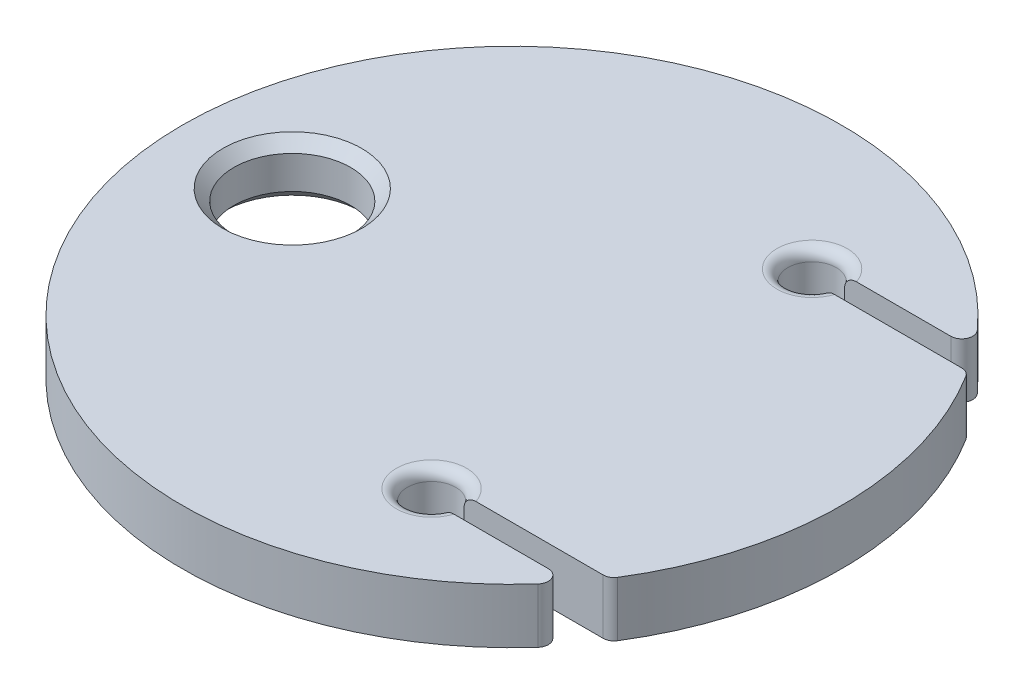
from build123d import *

# Parameters (mm, degrees)
SKETCH1_R             = 19.05
BOSS_EXTRUDE1_DEPTH   = 3.175
TIEDOWN_HOLE_D        = 6.7564
MONOFILAMENT_HOLE_D   = 2.794
MONOFILAMENT_HOLE_2_D = 2.794
CHAMFER1_SIZE         = 0.635
SKETCH10_W            = 1.27
SKETCH10_H            = 12.7
CUT_EXTRUDE1_DEPTH    = 13.7
FILLET1_R             = 0.635


with BuildPart() as part:
    # Sketch1 → Boss-Extrude1 (new body)
    with BuildSketch(Plane(origin=(0, 0, 0), x_dir=(1, 0, 0), z_dir=(0, 1, 0))):
        Circle(SKETCH1_R)
    extrude(amount=BOSS_EXTRUDE1_DEPTH)

    # Tiedown Hole (through all)
    with Locations(Plane(origin=(0, 3.175, 0), x_dir=(1, 0, 0), z_dir=(0, 1, 0))):
        with Locations((-12.7, 0)):
            Hole(TIEDOWN_HOLE_D / 2)

    # Monofilament Hole (through all)
    with Locations(Plane(origin=(0, 3.175, 0), x_dir=(-1, 0, 0), z_dir=(0, 1, 0))):
        with Locations((-6.35, -10.998522628)):
            Hole(MONOFILAMENT_HOLE_D / 2)

    # Monofilament Hole 2 (through all)
    with Locations(Plane(origin=(0, 3.175, 0), x_dir=(1, 0, 0), z_dir=(0, 1, 0))):
        with Locations((6.35, -10.998522628)):
            Hole(MONOFILAMENT_HOLE_2_D / 2)

    # Chamfer1
    chamfer1_edges = [part.edges().sort_by_distance(p)[0] for p in [
        (-9.3218, 3.175, 0),
        (-9.3218, 0, 0),
    ]]
    chamfer(chamfer1_edges, length=CHAMFER1_SIZE)

    # Sketch10 → Cut-Extrude1 (cut, through all)
    with BuildSketch(Plane(origin=(6.35, 6.35, 0), x_dir=(0, 0, 1), z_dir=(1, 0, 0))):
        with Locations((10.998522628, 3.175)):
            Rectangle(SKETCH10_W, SKETCH10_H)
        with Locations((-10.998522628, 3.175)):
            Rectangle(SKETCH10_W, SKETCH10_H)
    extrude(amount=CUT_EXTRUDE1_DEPTH, mode=Mode.SUBTRACT)

    # Fillet1
    fillet1_edges = [part.edges().sort_by_distance(p)[0] for p in [
        (4.953, 0, 10.998522628),
        (4.953, 3.175, 10.998522628),
        (4.953, 0, -10.998522628),
        (4.953, 3.175, -10.998522628),
        (15.984364196, 1.5875, 10.363522628),
        (15.085213, 1.5875, 11.633522628),
        (15.984364196, 1.5875, -10.363522628),
        (15.085213, 1.5875, -11.633522628),
    ]]
    fillet(fillet1_edges, radius=FILLET1_R)


solid = part.part
